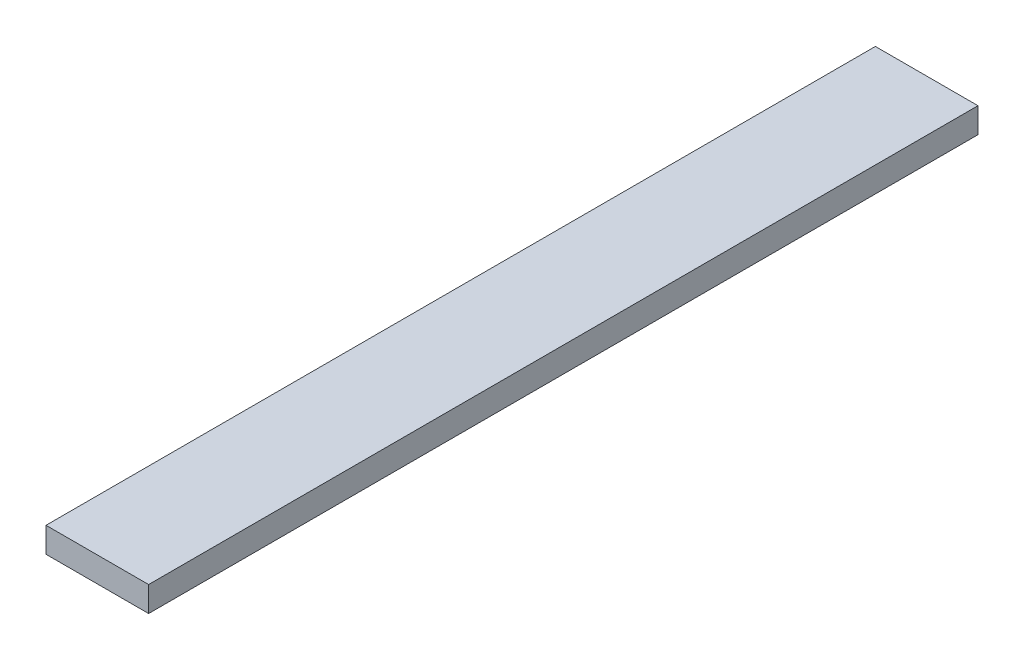
from build123d import *

# Parameters (mm, degrees)
SKETCH1_W           = 24.5
SKETCH1_H           = 198
BOSS_EXTRUDE1_DEPTH = 6


with BuildPart() as part:
    # Sketch1 → Boss-Extrude1 (new body)
    with BuildSketch(Plane(origin=(0, 0, 0), x_dir=(1, 0, 0), z_dir=(0, 1, 0))):
        with Locations((-44.815217391, 67.47826087)):
            Rectangle(SKETCH1_W, SKETCH1_H)
    extrude(amount=BOSS_EXTRUDE1_DEPTH)


solid = part.part
